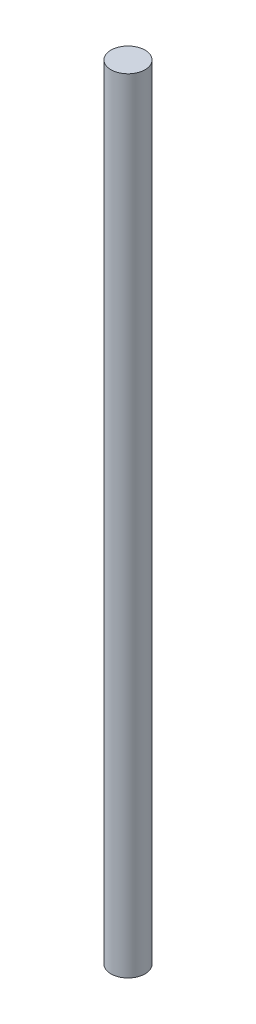
from build123d import *

# Parameters (mm, degrees)
SKETCH1_R           = 12.7
BOSS_EXTRUDE1_DEPTH = 584.2


with BuildPart() as part:
    # Sketch1 → Boss-Extrude1 (new body)
    with BuildSketch(Plane(origin=(0, 0, 0), x_dir=(1, 0, 0), z_dir=(0, 1, 0))):
        Circle(SKETCH1_R)
    extrude(amount=BOSS_EXTRUDE1_DEPTH)


solid = part.part
